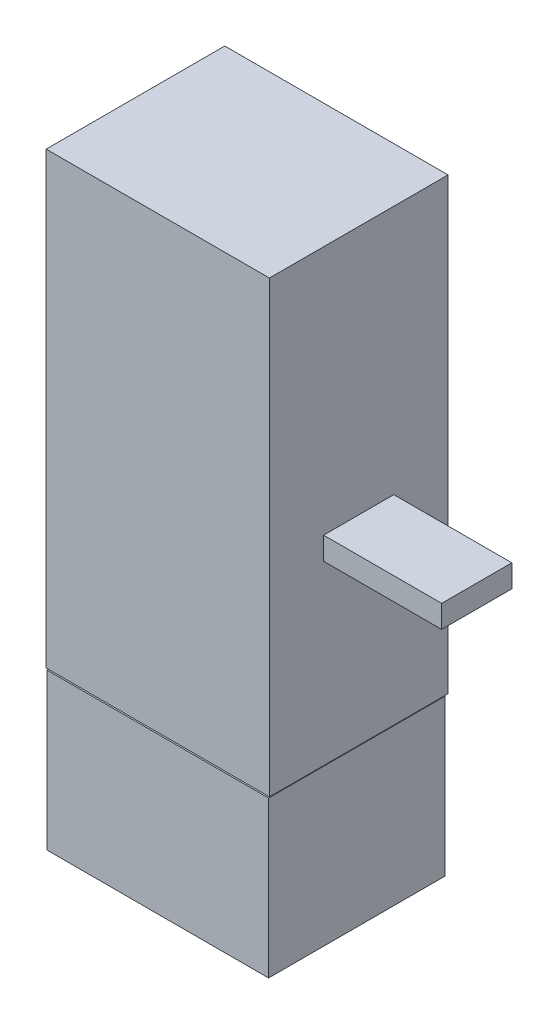
from build123d import *

# Parameters (mm, degrees)
SCHIZZO3_W                   = 980.000030518
SCHIZZO3_H                   = 780
ESTRUSIONE_ESTRUSIONE1_DEPTH = 689.31
SCHIZZO1_W                   = 987.653640747
SCHIZZO1_H                   = 1987.653686524
ESTRUSIONE_ESTRUSIONE2_DEPTH = 790.06
SCHIZZO4_W                   = 310.453109737
SCHIZZO4_H                   = 99.8660353
ESTRUSIONE_ESTRUSIONE3_DEPTH = 526


with BuildPart() as part:
    # Schizzo3 → Estrusione-Estrusione1 (new body)
    with BuildSketch(Plane(origin=(0, -1550, 0), x_dir=(1, 0, 0), z_dir=(0, 1, 0))):
        with Locations((254.138900757, -2000)):
            Rectangle(SCHIZZO3_W, SCHIZZO3_H)
    extrude(amount=ESTRUSIONE_ESTRUSIONE1_DEPTH)


with BuildPart() as body_2:
    # Schizzo1 → Estrusione-Estrusione2 (new body)
    with BuildSketch(Plane.XY.offset(1599.94)):
        with Locations((254.138877869, 139.687561035)):
            Rectangle(SCHIZZO1_W, SCHIZZO1_H)
    extrude(amount=ESTRUSIONE_ESTRUSIONE2_DEPTH)

    # Schizzo4 → Estrusione-Estrusione3 (add)
    with BuildSketch(Plane(origin=(744.138916016, 0, 0), x_dir=(0, 0, -1), z_dir=(1, 0, 0))):
        with Locations((-1995.111069738, -21.422412686)):
            Rectangle(SCHIZZO4_W, SCHIZZO4_H)
    extrude(amount=ESTRUSIONE_ESTRUSIONE3_DEPTH)


solid = Compound([part.part, body_2.part])
